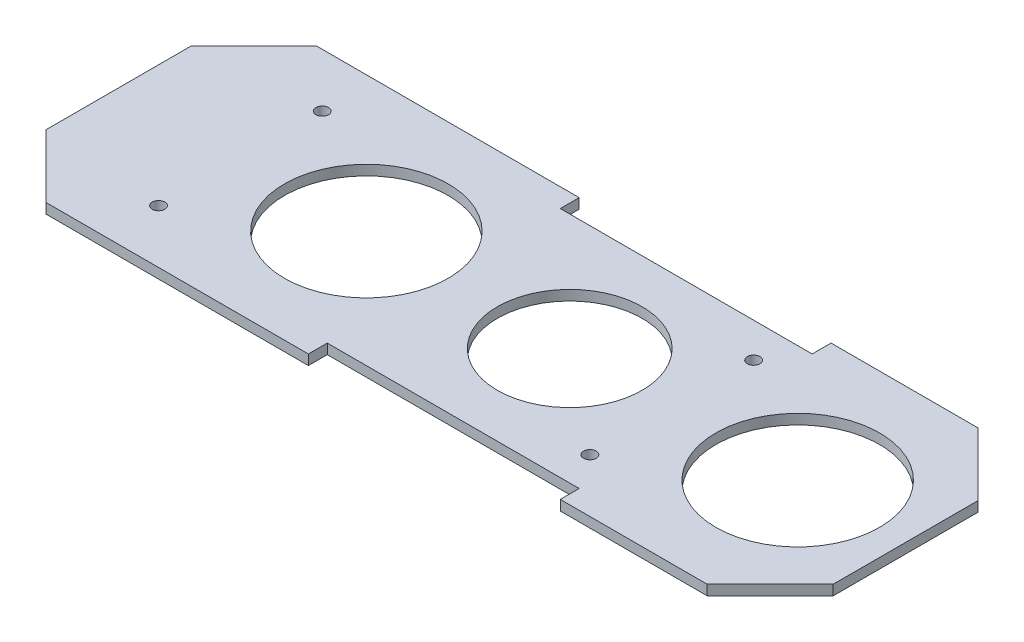
from build123d import *

# Parameters (mm, degrees)
SKETCH2_R           = 1
SKETCH2_R_2         = 13
SKETCH2_R_3         = 11.5
BOSS_EXTRUDE1_DEPTH = 1.6
CHAMFER1_SIZE       = 10


with BuildPart() as part:
    # Sketch2 → Boss-Extrude1 (new body)
    with BuildSketch(Plane(origin=(0, 0, 0), x_dir=(1, 0, 0), z_dir=(0, 1, 0))):
        Polygon((0, 21.5), (51.666666667, 21.5), (51.666666667, 18.5), (91.666666667, 18.5), (91.666666667, 21.5), (125, 21.5), (125, -21.5), (91.666666667, -21.5), (91.666666667, -18.5), (51.666666667, -18.5), (51.666666667, -21.5), (0, -21.5), align=None)
        with Locations((19.37, 13)):
            Circle(SKETCH2_R, mode=Mode.SUBTRACT)
        with Locations((87.87, 13)):
            Circle(SKETCH2_R, mode=Mode.SUBTRACT)
        with Locations((87.87, -13)):
            Circle(SKETCH2_R, mode=Mode.SUBTRACT)
        with Locations((19.37, -13)):
            Circle(SKETCH2_R, mode=Mode.SUBTRACT)
        with Locations((39.37, 0)):
            Circle(SKETCH2_R_2, mode=Mode.SUBTRACT)
        with Locations((107.87, 0)):
            Circle(SKETCH2_R_2, mode=Mode.SUBTRACT)
        with Locations((71.666666667, 0)):
            Circle(SKETCH2_R_3, mode=Mode.SUBTRACT)
    extrude(amount=BOSS_EXTRUDE1_DEPTH)

    # Chamfer1
    chamfer1_edges = [part.edges().sort_by_distance(p)[0] for p in [
        (0, 0.8, 21.5),
        (0, 0.8, -21.5),
        (125, 0.8, -21.5),
        (125, 0.8, 21.5),
    ]]
    chamfer(chamfer1_edges, length=CHAMFER1_SIZE)


solid = part.part
